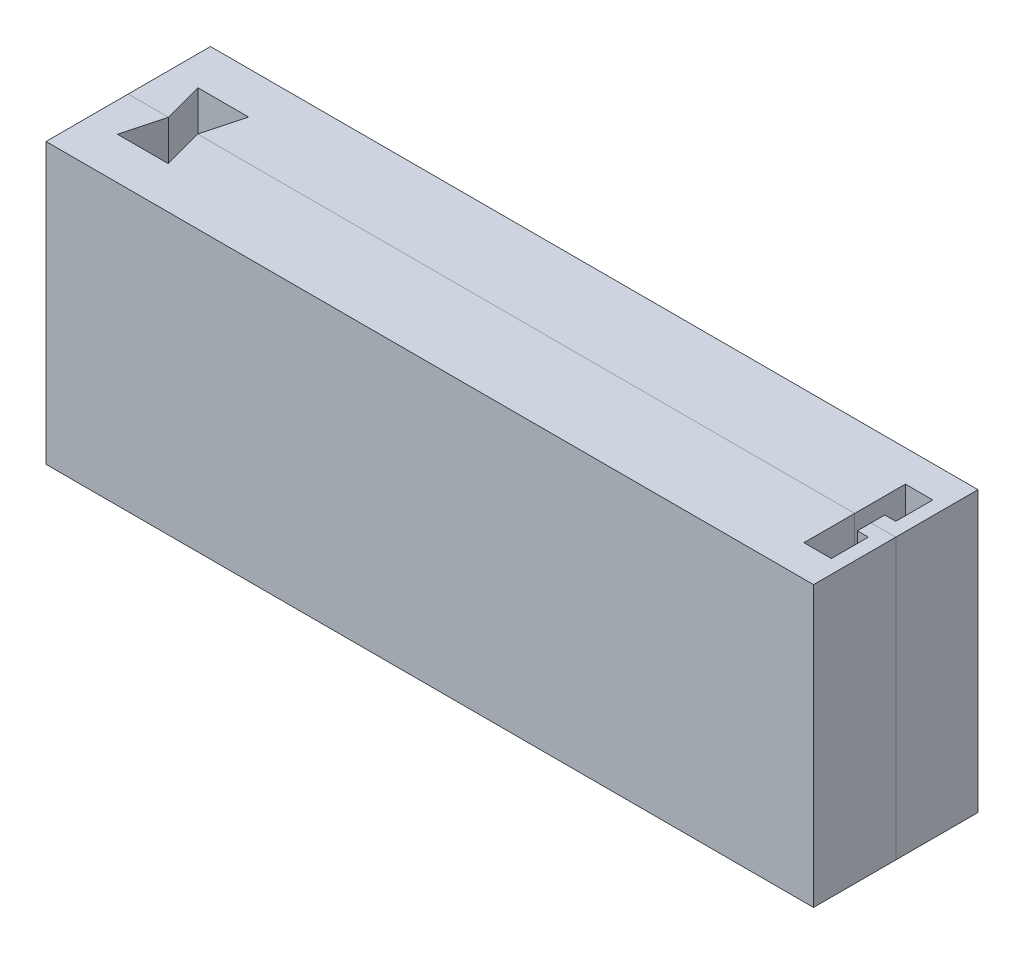
from build123d import *

# Parameters (mm, degrees)
SKETCH1_W               = 140
SKETCH1_H               = 51
BOSS_EXTRUDE1_DEPTH     = 15
CUT_EXTRUDE1_DEPTH      = 52
CUT_EXTRUDE2_DEPTH      = 1
CUT_EXTRUDE2_DEPTH_BACK = 26


with BuildPart() as part:
    # Sketch1 → Boss-Extrude1 (new body)
    with BuildSketch(Plane.XY):
        with Locations((9.063380282, 3.112676056)):
            Rectangle(SKETCH1_W, SKETCH1_H)
    extrude(amount=BOSS_EXTRUDE1_DEPTH)

    # Sketch2 → Cut-Extrude1 (cut, through all)
    with BuildSketch(Plane(origin=(0, 28.612676056, 0), x_dir=(1, 0, 0), z_dir=(0, 1, 0))):
        Polygon((74.563380282, -2.5), (74.563380282, 0), (71.563380282, 0), (71.563380282, -2.5), (71.563380282, -9.25), (76.563380282, -9.25), (76.563380282, -2.5), align=None)
    extrude(amount=-CUT_EXTRUDE1_DEPTH, mode=Mode.SUBTRACT)

    # Sketch3 → Cut-Extrude2 (cut, two sides)
    with BuildSketch(Plane(origin=(0, 28.612676056, 0), x_dir=(1, 0, 0), z_dir=(0, 1, 0))) as cut_extrude2_sk:
        Polygon((-352.539176525, 0), (-60.936619718, 0), (-53.586619718, 0), (-55.553644461, -7.34103628), (-46.319594976, -7.34103628), (-48.286619718, 0), (-123.75891502, 281.666440631), (-576.450550722, 649.359910128), (-805.230812226, 367.693469497), align=None)
    extrude(amount=CUT_EXTRUDE2_DEPTH, mode=Mode.SUBTRACT)
    extrude(cut_extrude2_sk.sketch, amount=-CUT_EXTRUDE2_DEPTH_BACK, mode=Mode.SUBTRACT)


with BuildPart() as body_2:
    # Mirror1: mirrored copy
    add(part.part.mirror(Plane.XY))


solid = Compound([part.part, body_2.part])
